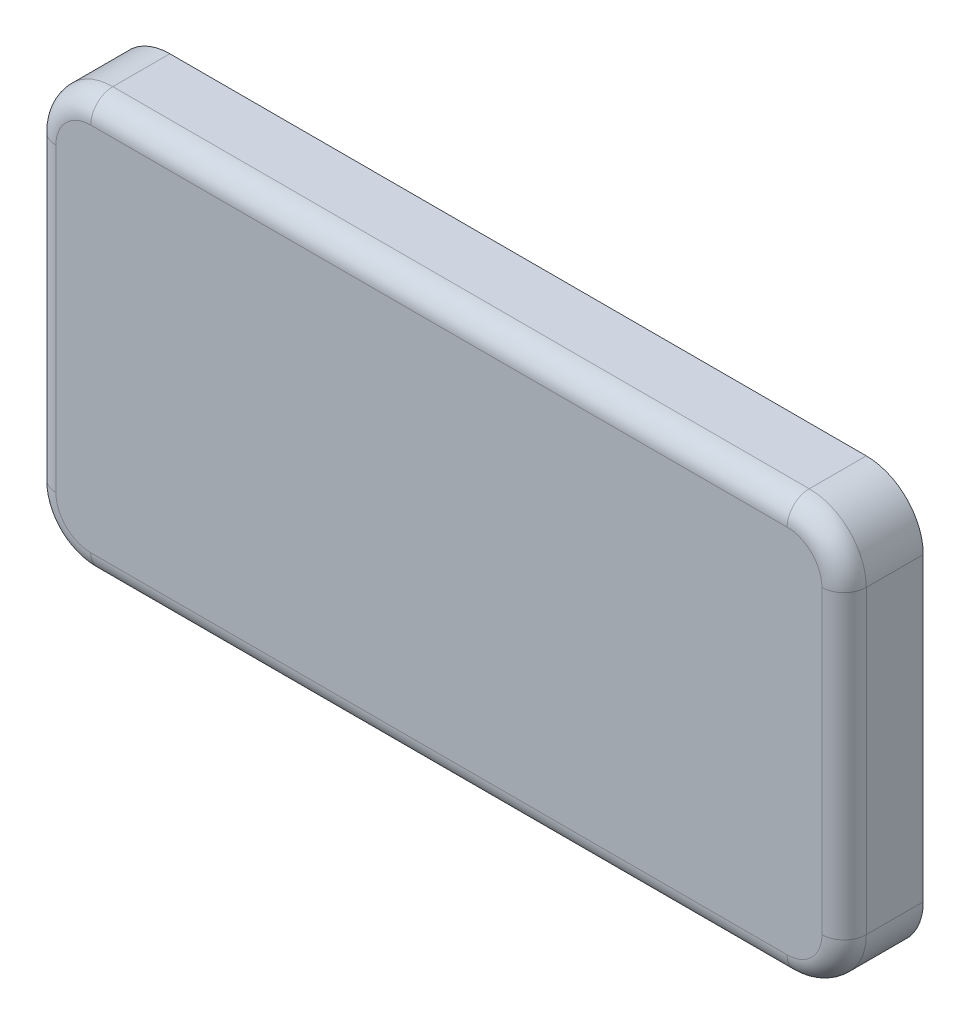
from build123d import *

# Parameters (mm, degrees)
SALIENTE_EXTRUIR1_DEPTH = 25
REDONDEO1_R             = 7
VACIADO1_T              = -3


with BuildPart() as part:
    # Croquis1 → Saliente-Extruir1 (new body)
    with BuildSketch(Plane.XY):
        with BuildLine():
            Line((-110, 65.5), (110, 65.5))
            ThreePointArc((110, 65.5), (122.727922061, 60.227922061), (128, 47.5))
            Line((128, 47.5), (128, -47.5))
            ThreePointArc((128, -47.5), (122.727922061, -60.227922061), (110, -65.5))
            Line((110, -65.5), (-110, -65.5))
            ThreePointArc((-110, -65.5), (-122.727922061, -60.227922061), (-128, -47.5))
            Line((-128, -47.5), (-128, 47.5))
            ThreePointArc((-128, 47.5), (-122.727922061, 60.227922061), (-110, 65.5))
        make_face()
    extrude(amount=SALIENTE_EXTRUIR1_DEPTH)

    # Redondeo1
    redondeo1_edges = [part.edges().sort_by_distance(p)[0] for p in [
        (-122.727922061, 60.227922061, 25),
        (-128, 0, 25),
        (-122.727922061, -60.227922061, 25),
        (0, -65.5, 25),
        (122.727922061, -60.227922061, 25),
        (128, 0, 25),
        (122.727922061, 60.227922061, 25),
        (0, 65.5, 25),
    ]]
    fillet(redondeo1_edges, radius=REDONDEO1_R)

    # Vaciado1
    vaciado1_openings = [part.faces().sort_by_distance(p)[0] for p in [
        (0, 0, 0),
    ]]
    offset(amount=VACIADO1_T, openings=vaciado1_openings, kind=Kind.INTERSECTION)


solid = part.part
